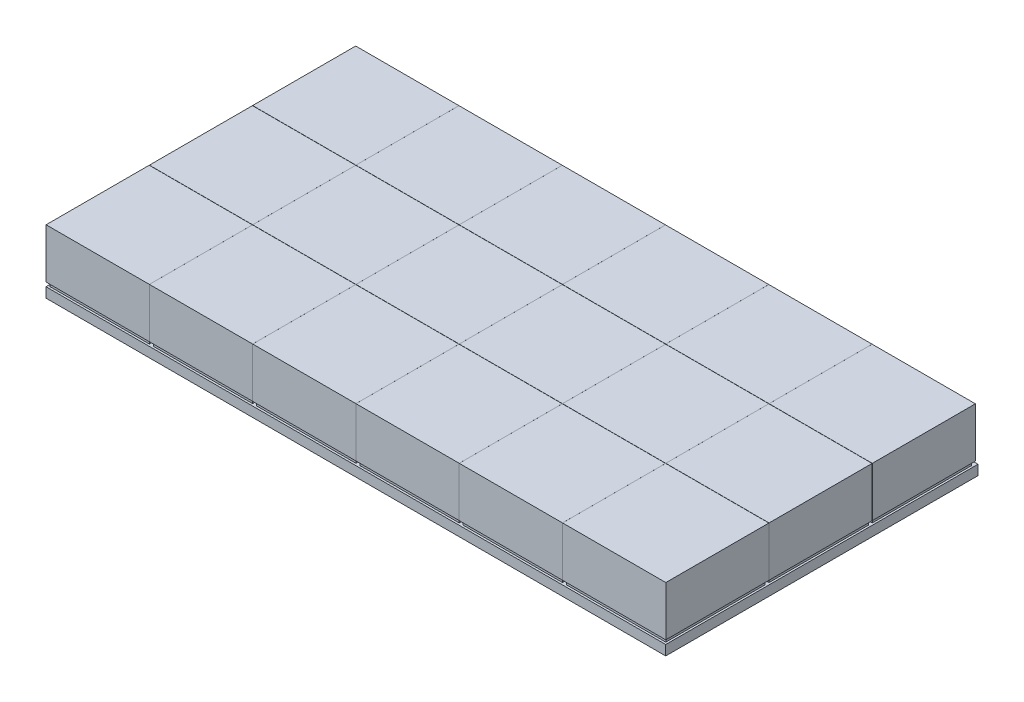
from build123d import *

# Parameters (mm, degrees)
SKETCH1_W                      = 480
SKETCH1_H                      = 270
BOSS_EXTRUDE1_DEPTH            = 5
SKETCH2_W                      = 50
SKETCH2_H                      = 50
BOSS_EXTRUDE3_DEPTH            = 2
LPATTERN1_COUNT                = 5
LPATTERN1_PITCH                = 52
SKETCH3_W                      = 52
SKETCH3_H                      = 51.9
BOSS_EXTRUDE8_DEPTH            = 25
LPATTERN5_COUNT                = 5
LPATTERN5_PITCH                = 52
LPATTERN6_COUNT                = 4
LPATTERN6_PITCH                = 52.01
LPATTERN6_COPY_1_SKETCH_W      = 50
LPATTERN6_COPY_1_SKETCH_H      = 50
LPATTERN6_COPY_1_DEPTH         = 2
LPATTERN6_COPY_2_SKETCH_W      = 50
LPATTERN6_COPY_2_SKETCH_H      = 50
LPATTERN6_COPY_2_DEPTH         = 2
LPATTERN6_COPY_3_SKETCH_W      = 50
LPATTERN6_COPY_3_SKETCH_H      = 50
LPATTERN6_COPY_3_DEPTH         = 2
LPATTERN6_COPY_4_SKETCH_W      = 50
LPATTERN6_COPY_4_SKETCH_H      = 50
LPATTERN6_COPY_4_DEPTH         = 2
LPATTERN6_COPY_5_SKETCH_W      = 50
LPATTERN6_COPY_5_SKETCH_H      = 50
LPATTERN6_COPY_5_DEPTH         = 2
LPATTERN6_COPY_6_SKETCH_W      = 50
LPATTERN6_COPY_6_SKETCH_H      = 50
LPATTERN6_COPY_6_DEPTH         = 2
LPATTERN6_COPY_7_SKETCH_W      = 50
LPATTERN6_COPY_7_SKETCH_H      = 50
LPATTERN6_COPY_7_DEPTH         = 2
LPATTERN6_COPY_8_SKETCH_W      = 50
LPATTERN6_COPY_8_SKETCH_H      = 50
LPATTERN6_COPY_8_DEPTH         = 2
LPATTERN6_COPY_9_SKETCH_W      = 50
LPATTERN6_COPY_9_SKETCH_H      = 50
LPATTERN6_COPY_9_DEPTH         = 2
LPATTERN6_COPY_10_SKETCH_W     = 50
LPATTERN6_COPY_10_SKETCH_H     = 50
LPATTERN6_COPY_10_DEPTH        = 2
LPATTERN6_COPY_11_SKETCH_W     = 50
LPATTERN6_COPY_11_SKETCH_H     = 50
LPATTERN6_COPY_11_DEPTH        = 2
LPATTERN6_COPY_12_SKETCH_W     = 50
LPATTERN6_COPY_12_SKETCH_H     = 50
LPATTERN6_COPY_12_DEPTH        = 2
LPATTERN6_COPY_13_SKETCH_W     = 52
LPATTERN6_COPY_13_SKETCH_H     = 51.9
LPATTERN6_COPY_13_DEPTH        = 25
LPATTERN6_COPY_14_SKETCH_W     = 52
LPATTERN6_COPY_14_SKETCH_H     = 51.9
LPATTERN6_COPY_14_DEPTH        = 25
LPATTERN6_COPY_15_SKETCH_W     = 52
LPATTERN6_COPY_15_SKETCH_H     = 51.9
LPATTERN6_COPY_15_DEPTH        = 25
LPATTERN6_COPY_16_SKETCH_W     = 52
LPATTERN6_COPY_16_SKETCH_H     = 51.9
LPATTERN6_COPY_16_DEPTH        = 25
LPATTERN6_COPY_17_SKETCH_W     = 52
LPATTERN6_COPY_17_SKETCH_H     = 51.9
LPATTERN6_COPY_17_DEPTH        = 25
LPATTERN6_COPY_18_SKETCH_W     = 52
LPATTERN6_COPY_18_SKETCH_H     = 51.9
LPATTERN6_COPY_18_DEPTH        = 25
LPATTERN6_COPY_19_SKETCH_W     = 52
LPATTERN6_COPY_19_SKETCH_H     = 51.9
LPATTERN6_COPY_19_DEPTH        = 25
LPATTERN6_COPY_20_SKETCH_W     = 52
LPATTERN6_COPY_20_SKETCH_H     = 51.9
LPATTERN6_COPY_20_DEPTH        = 25
LPATTERN6_COPY_21_SKETCH_W     = 52
LPATTERN6_COPY_21_SKETCH_H     = 51.9
LPATTERN6_COPY_21_DEPTH        = 25
LPATTERN6_COPY_22_SKETCH_W     = 52
LPATTERN6_COPY_22_SKETCH_H     = 51.9
LPATTERN6_COPY_22_DEPTH        = 25
LPATTERN6_COPY_23_SKETCH_W     = 52
LPATTERN6_COPY_23_SKETCH_H     = 51.9
LPATTERN6_COPY_23_DEPTH        = 25
LPATTERN6_COPY_24_SKETCH_W     = 52
LPATTERN6_COPY_24_SKETCH_H     = 51.9
LPATTERN6_COPY_24_DEPTH        = 25
LPATTERN6_COL_COUNT            = 5
LPATTERN6_COL_PITCH            = 52.01
LPATTERN6_COL_COPY_1_SKETCH_W  = 50
LPATTERN6_COL_COPY_1_SKETCH_H  = 50
LPATTERN6_COL_COPY_1_DEPTH     = 2
LPATTERN6_COL_COPY_2_SKETCH_W  = 50
LPATTERN6_COL_COPY_2_SKETCH_H  = 50
LPATTERN6_COL_COPY_2_DEPTH     = 2
LPATTERN6_COL_COPY_3_SKETCH_W  = 50
LPATTERN6_COL_COPY_3_SKETCH_H  = 50
LPATTERN6_COL_COPY_3_DEPTH     = 2
LPATTERN6_COL_COPY_4_SKETCH_W  = 50
LPATTERN6_COL_COPY_4_SKETCH_H  = 50
LPATTERN6_COL_COPY_4_DEPTH     = 2
LPATTERN6_COL_COPY_5_SKETCH_W  = 50
LPATTERN6_COL_COPY_5_SKETCH_H  = 50
LPATTERN6_COL_COPY_5_DEPTH     = 2
LPATTERN6_COL_COPY_6_SKETCH_W  = 50
LPATTERN6_COL_COPY_6_SKETCH_H  = 50
LPATTERN6_COL_COPY_6_DEPTH     = 2
LPATTERN6_COL_COPY_7_SKETCH_W  = 50
LPATTERN6_COL_COPY_7_SKETCH_H  = 50
LPATTERN6_COL_COPY_7_DEPTH     = 2
LPATTERN6_COL_COPY_8_SKETCH_W  = 50
LPATTERN6_COL_COPY_8_SKETCH_H  = 50
LPATTERN6_COL_COPY_8_DEPTH     = 2
LPATTERN6_COL_COPY_9_SKETCH_W  = 50
LPATTERN6_COL_COPY_9_SKETCH_H  = 50
LPATTERN6_COL_COPY_9_DEPTH     = 2
LPATTERN6_COL_COPY_10_SKETCH_W = 50
LPATTERN6_COL_COPY_10_SKETCH_H = 50
LPATTERN6_COL_COPY_10_DEPTH    = 2
LPATTERN6_COL_COPY_11_SKETCH_W = 50
LPATTERN6_COL_COPY_11_SKETCH_H = 50
LPATTERN6_COL_COPY_11_DEPTH    = 2
LPATTERN6_COL_COPY_12_SKETCH_W = 50
LPATTERN6_COL_COPY_12_SKETCH_H = 50
LPATTERN6_COL_COPY_12_DEPTH    = 2
LPATTERN6_COL_COPY_13_SKETCH_W = 50
LPATTERN6_COL_COPY_13_SKETCH_H = 50
LPATTERN6_COL_COPY_13_DEPTH    = 2
LPATTERN6_COL_COPY_14_SKETCH_W = 50
LPATTERN6_COL_COPY_14_SKETCH_H = 50
LPATTERN6_COL_COPY_14_DEPTH    = 2
LPATTERN6_COL_COPY_15_SKETCH_W = 50
LPATTERN6_COL_COPY_15_SKETCH_H = 50
LPATTERN6_COL_COPY_15_DEPTH    = 2
LPATTERN6_COL_COPY_16_SKETCH_W = 50
LPATTERN6_COL_COPY_16_SKETCH_H = 50
LPATTERN6_COL_COPY_16_DEPTH    = 2
LPATTERN6_COL_COPY_17_SKETCH_W = 52
LPATTERN6_COL_COPY_17_SKETCH_H = 51.9
LPATTERN6_COL_COPY_17_DEPTH    = 25
LPATTERN6_COL_COPY_18_SKETCH_W = 52
LPATTERN6_COL_COPY_18_SKETCH_H = 51.9
LPATTERN6_COL_COPY_18_DEPTH    = 25
LPATTERN6_COL_COPY_19_SKETCH_W = 52
LPATTERN6_COL_COPY_19_SKETCH_H = 51.9
LPATTERN6_COL_COPY_19_DEPTH    = 25
LPATTERN6_COL_COPY_20_SKETCH_W = 52
LPATTERN6_COL_COPY_20_SKETCH_H = 51.9
LPATTERN6_COL_COPY_20_DEPTH    = 25
LPATTERN6_COL_COPY_21_SKETCH_W = 52
LPATTERN6_COL_COPY_21_SKETCH_H = 51.9
LPATTERN6_COL_COPY_21_DEPTH    = 25
LPATTERN6_COL_COPY_22_SKETCH_W = 52
LPATTERN6_COL_COPY_22_SKETCH_H = 51.9
LPATTERN6_COL_COPY_22_DEPTH    = 25
LPATTERN6_COL_COPY_23_SKETCH_W = 52
LPATTERN6_COL_COPY_23_SKETCH_H = 51.9
LPATTERN6_COL_COPY_23_DEPTH    = 25
LPATTERN6_COL_COPY_24_SKETCH_W = 52
LPATTERN6_COL_COPY_24_SKETCH_H = 51.9
LPATTERN6_COL_COPY_24_DEPTH    = 25
LPATTERN6_COL_COPY_25_SKETCH_W = 52
LPATTERN6_COL_COPY_25_SKETCH_H = 51.9
LPATTERN6_COL_COPY_25_DEPTH    = 25
LPATTERN6_COL_COPY_26_SKETCH_W = 52
LPATTERN6_COL_COPY_26_SKETCH_H = 51.9
LPATTERN6_COL_COPY_26_DEPTH    = 25
LPATTERN6_COL_COPY_27_SKETCH_W = 52
LPATTERN6_COL_COPY_27_SKETCH_H = 51.9
LPATTERN6_COL_COPY_27_DEPTH    = 25
LPATTERN6_COL_COPY_28_SKETCH_W = 52
LPATTERN6_COL_COPY_28_SKETCH_H = 51.9
LPATTERN6_COL_COPY_28_DEPTH    = 25
LPATTERN6_COL_COPY_29_SKETCH_W = 52
LPATTERN6_COL_COPY_29_SKETCH_H = 51.9
LPATTERN6_COL_COPY_29_DEPTH    = 25
LPATTERN6_COL_COPY_30_SKETCH_W = 52
LPATTERN6_COL_COPY_30_SKETCH_H = 51.9
LPATTERN6_COL_COPY_30_DEPTH    = 25
LPATTERN6_COL_COPY_31_SKETCH_W = 52
LPATTERN6_COL_COPY_31_SKETCH_H = 51.9
LPATTERN6_COL_COPY_31_DEPTH    = 25
LPATTERN6_COL_COPY_32_SKETCH_W = 52
LPATTERN6_COL_COPY_32_SKETCH_H = 51.9
LPATTERN6_COL_COPY_32_DEPTH    = 25
SKETCH4_W                      = 57.965863992
SKETCH4_H                      = 270
SKETCH4_W_2                    = 109.974703244
SKETCH4_H_2                    = 270.550723286
CUT_EXTRUDE1_DEPTH             = 28
CUT_EXTRUDE1_DEPTH_BACK        = 6
SKETCH5_W                      = 312.059432764
SKETCH5_H                      = 107.948510905
SKETCH5_W_2                    = 312.059780671
SKETCH5_H_2                    = 4.790225888
CUT_EXTRUDE2_DEPTH             = 28
CUT_EXTRUDE2_DEPTH_BACK        = 6


with BuildPart() as part:
    # Sketch1 → Boss-Extrude1 (new body)
    with BuildSketch(Plane(origin=(0, 0, 0), x_dir=(1, 0, 0), z_dir=(0, 1, 0))):
        Rectangle(SKETCH1_W, SKETCH1_H)
    extrude(amount=BOSS_EXTRUDE1_DEPTH)

    # Sketch2 → Boss-Extrude3 (add)
    with BuildSketch(Plane(origin=(0, 5, 0), x_dir=(1, 0, 0), z_dir=(0, 1, 0))):
        with Locations((0, -105)):
            Rectangle(SKETCH2_W, SKETCH2_H)
    boss_extrude3 = extrude(amount=BOSS_EXTRUDE3_DEPTH)

    # LPattern1: Boss-Extrude3 ×5
    with Locations(*[(0, 0, -i * LPATTERN1_PITCH) for i in range(1, LPATTERN1_COUNT)]):
        add(boss_extrude3)

    # Sketch3 → Boss-Extrude8 (add)
    with BuildSketch(Plane(origin=(0, 7, 0), x_dir=(1, 0, 0), z_dir=(0, 1, 0))):
        with Locations((0, -105.05)):
            Rectangle(SKETCH3_W, SKETCH3_H)
    boss_extrude8 = extrude(amount=BOSS_EXTRUDE8_DEPTH)

    # LPattern5: Boss-Extrude8 ×5
    with Locations(*[(0, 0, -i * LPATTERN5_PITCH) for i in range(1, LPATTERN5_COUNT)]):
        add(boss_extrude8)

    # LPattern6: Boss-Extrude3, Boss-Extrude8 ×4
    with Locations(*[(i * LPATTERN6_PITCH, 0, 0) for i in range(1, LPATTERN6_COUNT)]):
        add(boss_extrude3)
        add(boss_extrude8)

    # LPattern6 copy 1 sketch → LPattern6 copy 1 (add)
    with BuildSketch(Plane(origin=(52.01, 5, -52), x_dir=(1, 0, 0), z_dir=(0, 1, 0))):
        with Locations((0, -105)):
            Rectangle(LPATTERN6_COPY_1_SKETCH_W, LPATTERN6_COPY_1_SKETCH_H)
    extrude(amount=LPATTERN6_COPY_1_DEPTH)

    # LPattern6 copy 2 sketch → LPattern6 copy 2 (add)
    with BuildSketch(Plane(origin=(104.02, 5, -52), x_dir=(1, 0, 0), z_dir=(0, 1, 0))):
        with Locations((0, -105)):
            Rectangle(LPATTERN6_COPY_2_SKETCH_W, LPATTERN6_COPY_2_SKETCH_H)
    extrude(amount=LPATTERN6_COPY_2_DEPTH)

    # LPattern6 copy 3 sketch → LPattern6 copy 3 (add)
    with BuildSketch(Plane(origin=(156.03, 5, -52), x_dir=(1, 0, 0), z_dir=(0, 1, 0))):
        with Locations((0, -105)):
            Rectangle(LPATTERN6_COPY_3_SKETCH_W, LPATTERN6_COPY_3_SKETCH_H)
    extrude(amount=LPATTERN6_COPY_3_DEPTH)

    # LPattern6 copy 4 sketch → LPattern6 copy 4 (add)
    with BuildSketch(Plane(origin=(52.01, 5, -104), x_dir=(1, 0, 0), z_dir=(0, 1, 0))):
        with Locations((0, -105)):
            Rectangle(LPATTERN6_COPY_4_SKETCH_W, LPATTERN6_COPY_4_SKETCH_H)
    extrude(amount=LPATTERN6_COPY_4_DEPTH)

    # LPattern6 copy 5 sketch → LPattern6 copy 5 (add)
    with BuildSketch(Plane(origin=(104.02, 5, -104), x_dir=(1, 0, 0), z_dir=(0, 1, 0))):
        with Locations((0, -105)):
            Rectangle(LPATTERN6_COPY_5_SKETCH_W, LPATTERN6_COPY_5_SKETCH_H)
    extrude(amount=LPATTERN6_COPY_5_DEPTH)

    # LPattern6 copy 6 sketch → LPattern6 copy 6 (add)
    with BuildSketch(Plane(origin=(156.03, 5, -104), x_dir=(1, 0, 0), z_dir=(0, 1, 0))):
        with Locations((0, -105)):
            Rectangle(LPATTERN6_COPY_6_SKETCH_W, LPATTERN6_COPY_6_SKETCH_H)
    extrude(amount=LPATTERN6_COPY_6_DEPTH)

    # LPattern6 copy 7 sketch → LPattern6 copy 7 (add)
    with BuildSketch(Plane(origin=(52.01, 5, -156), x_dir=(1, 0, 0), z_dir=(0, 1, 0))):
        with Locations((0, -105)):
            Rectangle(LPATTERN6_COPY_7_SKETCH_W, LPATTERN6_COPY_7_SKETCH_H)
    extrude(amount=LPATTERN6_COPY_7_DEPTH)

    # LPattern6 copy 8 sketch → LPattern6 copy 8 (add)
    with BuildSketch(Plane(origin=(104.02, 5, -156), x_dir=(1, 0, 0), z_dir=(0, 1, 0))):
        with Locations((0, -105)):
            Rectangle(LPATTERN6_COPY_8_SKETCH_W, LPATTERN6_COPY_8_SKETCH_H)
    extrude(amount=LPATTERN6_COPY_8_DEPTH)

    # LPattern6 copy 9 sketch → LPattern6 copy 9 (add)
    with BuildSketch(Plane(origin=(156.03, 5, -156), x_dir=(1, 0, 0), z_dir=(0, 1, 0))):
        with Locations((0, -105)):
            Rectangle(LPATTERN6_COPY_9_SKETCH_W, LPATTERN6_COPY_9_SKETCH_H)
    extrude(amount=LPATTERN6_COPY_9_DEPTH)

    # LPattern6 copy 10 sketch → LPattern6 copy 10 (add)
    with BuildSketch(Plane(origin=(52.01, 5, -208), x_dir=(1, 0, 0), z_dir=(0, 1, 0))):
        with Locations((0, -105)):
            Rectangle(LPATTERN6_COPY_10_SKETCH_W, LPATTERN6_COPY_10_SKETCH_H)
    extrude(amount=LPATTERN6_COPY_10_DEPTH)

    # LPattern6 copy 11 sketch → LPattern6 copy 11 (add)
    with BuildSketch(Plane(origin=(104.02, 5, -208), x_dir=(1, 0, 0), z_dir=(0, 1, 0))):
        with Locations((0, -105)):
            Rectangle(LPATTERN6_COPY_11_SKETCH_W, LPATTERN6_COPY_11_SKETCH_H)
    extrude(amount=LPATTERN6_COPY_11_DEPTH)

    # LPattern6 copy 12 sketch → LPattern6 copy 12 (add)
    with BuildSketch(Plane(origin=(156.03, 5, -208), x_dir=(1, 0, 0), z_dir=(0, 1, 0))):
        with Locations((0, -105)):
            Rectangle(LPATTERN6_COPY_12_SKETCH_W, LPATTERN6_COPY_12_SKETCH_H)
    extrude(amount=LPATTERN6_COPY_12_DEPTH)

    # LPattern6 copy 13 sketch → LPattern6 copy 13 (add)
    with BuildSketch(Plane(origin=(52.01, 7, -52), x_dir=(1, 0, 0), z_dir=(0, 1, 0))):
        with Locations((0, -105.05)):
            Rectangle(LPATTERN6_COPY_13_SKETCH_W, LPATTERN6_COPY_13_SKETCH_H)
    extrude(amount=LPATTERN6_COPY_13_DEPTH)

    # LPattern6 copy 14 sketch → LPattern6 copy 14 (add)
    with BuildSketch(Plane(origin=(104.02, 7, -52), x_dir=(1, 0, 0), z_dir=(0, 1, 0))):
        with Locations((0, -105.05)):
            Rectangle(LPATTERN6_COPY_14_SKETCH_W, LPATTERN6_COPY_14_SKETCH_H)
    extrude(amount=LPATTERN6_COPY_14_DEPTH)

    # LPattern6 copy 15 sketch → LPattern6 copy 15 (add)
    with BuildSketch(Plane(origin=(156.03, 7, -52), x_dir=(1, 0, 0), z_dir=(0, 1, 0))):
        with Locations((0, -105.05)):
            Rectangle(LPATTERN6_COPY_15_SKETCH_W, LPATTERN6_COPY_15_SKETCH_H)
    extrude(amount=LPATTERN6_COPY_15_DEPTH)

    # LPattern6 copy 16 sketch → LPattern6 copy 16 (add)
    with BuildSketch(Plane(origin=(52.01, 7, -104), x_dir=(1, 0, 0), z_dir=(0, 1, 0))):
        with Locations((0, -105.05)):
            Rectangle(LPATTERN6_COPY_16_SKETCH_W, LPATTERN6_COPY_16_SKETCH_H)
    extrude(amount=LPATTERN6_COPY_16_DEPTH)

    # LPattern6 copy 17 sketch → LPattern6 copy 17 (add)
    with BuildSketch(Plane(origin=(104.02, 7, -104), x_dir=(1, 0, 0), z_dir=(0, 1, 0))):
        with Locations((0, -105.05)):
            Rectangle(LPATTERN6_COPY_17_SKETCH_W, LPATTERN6_COPY_17_SKETCH_H)
    extrude(amount=LPATTERN6_COPY_17_DEPTH)

    # LPattern6 copy 18 sketch → LPattern6 copy 18 (add)
    with BuildSketch(Plane(origin=(156.03, 7, -104), x_dir=(1, 0, 0), z_dir=(0, 1, 0))):
        with Locations((0, -105.05)):
            Rectangle(LPATTERN6_COPY_18_SKETCH_W, LPATTERN6_COPY_18_SKETCH_H)
    extrude(amount=LPATTERN6_COPY_18_DEPTH)

    # LPattern6 copy 19 sketch → LPattern6 copy 19 (add)
    with BuildSketch(Plane(origin=(52.01, 7, -156), x_dir=(1, 0, 0), z_dir=(0, 1, 0))):
        with Locations((0, -105.05)):
            Rectangle(LPATTERN6_COPY_19_SKETCH_W, LPATTERN6_COPY_19_SKETCH_H)
    extrude(amount=LPATTERN6_COPY_19_DEPTH)

    # LPattern6 copy 20 sketch → LPattern6 copy 20 (add)
    with BuildSketch(Plane(origin=(104.02, 7, -156), x_dir=(1, 0, 0), z_dir=(0, 1, 0))):
        with Locations((0, -105.05)):
            Rectangle(LPATTERN6_COPY_20_SKETCH_W, LPATTERN6_COPY_20_SKETCH_H)
    extrude(amount=LPATTERN6_COPY_20_DEPTH)

    # LPattern6 copy 21 sketch → LPattern6 copy 21 (add)
    with BuildSketch(Plane(origin=(156.03, 7, -156), x_dir=(1, 0, 0), z_dir=(0, 1, 0))):
        with Locations((0, -105.05)):
            Rectangle(LPATTERN6_COPY_21_SKETCH_W, LPATTERN6_COPY_21_SKETCH_H)
    extrude(amount=LPATTERN6_COPY_21_DEPTH)

    # LPattern6 copy 22 sketch → LPattern6 copy 22 (add)
    with BuildSketch(Plane(origin=(52.01, 7, -208), x_dir=(1, 0, 0), z_dir=(0, 1, 0))):
        with Locations((0, -105.05)):
            Rectangle(LPATTERN6_COPY_22_SKETCH_W, LPATTERN6_COPY_22_SKETCH_H)
    extrude(amount=LPATTERN6_COPY_22_DEPTH)

    # LPattern6 copy 23 sketch → LPattern6 copy 23 (add)
    with BuildSketch(Plane(origin=(104.02, 7, -208), x_dir=(1, 0, 0), z_dir=(0, 1, 0))):
        with Locations((0, -105.05)):
            Rectangle(LPATTERN6_COPY_23_SKETCH_W, LPATTERN6_COPY_23_SKETCH_H)
    extrude(amount=LPATTERN6_COPY_23_DEPTH)

    # LPattern6 copy 24 sketch → LPattern6 copy 24 (add)
    with BuildSketch(Plane(origin=(156.03, 7, -208), x_dir=(1, 0, 0), z_dir=(0, 1, 0))):
        with Locations((0, -105.05)):
            Rectangle(LPATTERN6_COPY_24_SKETCH_W, LPATTERN6_COPY_24_SKETCH_H)
    extrude(amount=LPATTERN6_COPY_24_DEPTH)

    # LPattern6 col: Boss-Extrude3, Boss-Extrude8 ×5
    with Locations(*[(-i * LPATTERN6_COL_PITCH, 0, 0) for i in range(1, LPATTERN6_COL_COUNT)]):
        add(boss_extrude3)
        add(boss_extrude8)

    # LPattern6 col copy 1 sketch → LPattern6 col copy 1 (add)
    with BuildSketch(Plane(origin=(-52.01, 5, -52), x_dir=(1, 0, 0), z_dir=(0, 1, 0))):
        with Locations((0, -105)):
            Rectangle(LPATTERN6_COL_COPY_1_SKETCH_W, LPATTERN6_COL_COPY_1_SKETCH_H)
    extrude(amount=LPATTERN6_COL_COPY_1_DEPTH)

    # LPattern6 col copy 2 sketch → LPattern6 col copy 2 (add)
    with BuildSketch(Plane(origin=(-104.02, 5, -52), x_dir=(1, 0, 0), z_dir=(0, 1, 0))):
        with Locations((0, -105)):
            Rectangle(LPATTERN6_COL_COPY_2_SKETCH_W, LPATTERN6_COL_COPY_2_SKETCH_H)
    extrude(amount=LPATTERN6_COL_COPY_2_DEPTH)

    # LPattern6 col copy 3 sketch → LPattern6 col copy 3 (add)
    with BuildSketch(Plane(origin=(-156.03, 5, -52), x_dir=(1, 0, 0), z_dir=(0, 1, 0))):
        with Locations((0, -105)):
            Rectangle(LPATTERN6_COL_COPY_3_SKETCH_W, LPATTERN6_COL_COPY_3_SKETCH_H)
    extrude(amount=LPATTERN6_COL_COPY_3_DEPTH)

    # LPattern6 col copy 4 sketch → LPattern6 col copy 4 (add)
    with BuildSketch(Plane(origin=(-208.04, 5, -52), x_dir=(1, 0, 0), z_dir=(0, 1, 0))):
        with Locations((0, -105)):
            Rectangle(LPATTERN6_COL_COPY_4_SKETCH_W, LPATTERN6_COL_COPY_4_SKETCH_H)
    extrude(amount=LPATTERN6_COL_COPY_4_DEPTH)

    # LPattern6 col copy 5 sketch → LPattern6 col copy 5 (add)
    with BuildSketch(Plane(origin=(-52.01, 5, -104), x_dir=(1, 0, 0), z_dir=(0, 1, 0))):
        with Locations((0, -105)):
            Rectangle(LPATTERN6_COL_COPY_5_SKETCH_W, LPATTERN6_COL_COPY_5_SKETCH_H)
    extrude(amount=LPATTERN6_COL_COPY_5_DEPTH)

    # LPattern6 col copy 6 sketch → LPattern6 col copy 6 (add)
    with BuildSketch(Plane(origin=(-104.02, 5, -104), x_dir=(1, 0, 0), z_dir=(0, 1, 0))):
        with Locations((0, -105)):
            Rectangle(LPATTERN6_COL_COPY_6_SKETCH_W, LPATTERN6_COL_COPY_6_SKETCH_H)
    extrude(amount=LPATTERN6_COL_COPY_6_DEPTH)

    # LPattern6 col copy 7 sketch → LPattern6 col copy 7 (add)
    with BuildSketch(Plane(origin=(-156.03, 5, -104), x_dir=(1, 0, 0), z_dir=(0, 1, 0))):
        with Locations((0, -105)):
            Rectangle(LPATTERN6_COL_COPY_7_SKETCH_W, LPATTERN6_COL_COPY_7_SKETCH_H)
    extrude(amount=LPATTERN6_COL_COPY_7_DEPTH)

    # LPattern6 col copy 8 sketch → LPattern6 col copy 8 (add)
    with BuildSketch(Plane(origin=(-208.04, 5, -104), x_dir=(1, 0, 0), z_dir=(0, 1, 0))):
        with Locations((0, -105)):
            Rectangle(LPATTERN6_COL_COPY_8_SKETCH_W, LPATTERN6_COL_COPY_8_SKETCH_H)
    extrude(amount=LPATTERN6_COL_COPY_8_DEPTH)

    # LPattern6 col copy 9 sketch → LPattern6 col copy 9 (add)
    with BuildSketch(Plane(origin=(-52.01, 5, -156), x_dir=(1, 0, 0), z_dir=(0, 1, 0))):
        with Locations((0, -105)):
            Rectangle(LPATTERN6_COL_COPY_9_SKETCH_W, LPATTERN6_COL_COPY_9_SKETCH_H)
    extrude(amount=LPATTERN6_COL_COPY_9_DEPTH)

    # LPattern6 col copy 10 sketch → LPattern6 col copy 10 (add)
    with BuildSketch(Plane(origin=(-104.02, 5, -156), x_dir=(1, 0, 0), z_dir=(0, 1, 0))):
        with Locations((0, -105)):
            Rectangle(LPATTERN6_COL_COPY_10_SKETCH_W, LPATTERN6_COL_COPY_10_SKETCH_H)
    extrude(amount=LPATTERN6_COL_COPY_10_DEPTH)

    # LPattern6 col copy 11 sketch → LPattern6 col copy 11 (add)
    with BuildSketch(Plane(origin=(-156.03, 5, -156), x_dir=(1, 0, 0), z_dir=(0, 1, 0))):
        with Locations((0, -105)):
            Rectangle(LPATTERN6_COL_COPY_11_SKETCH_W, LPATTERN6_COL_COPY_11_SKETCH_H)
    extrude(amount=LPATTERN6_COL_COPY_11_DEPTH)

    # LPattern6 col copy 12 sketch → LPattern6 col copy 12 (add)
    with BuildSketch(Plane(origin=(-208.04, 5, -156), x_dir=(1, 0, 0), z_dir=(0, 1, 0))):
        with Locations((0, -105)):
            Rectangle(LPATTERN6_COL_COPY_12_SKETCH_W, LPATTERN6_COL_COPY_12_SKETCH_H)
    extrude(amount=LPATTERN6_COL_COPY_12_DEPTH)

    # LPattern6 col copy 13 sketch → LPattern6 col copy 13 (add)
    with BuildSketch(Plane(origin=(-52.01, 5, -208), x_dir=(1, 0, 0), z_dir=(0, 1, 0))):
        with Locations((0, -105)):
            Rectangle(LPATTERN6_COL_COPY_13_SKETCH_W, LPATTERN6_COL_COPY_13_SKETCH_H)
    extrude(amount=LPATTERN6_COL_COPY_13_DEPTH)

    # LPattern6 col copy 14 sketch → LPattern6 col copy 14 (add)
    with BuildSketch(Plane(origin=(-104.02, 5, -208), x_dir=(1, 0, 0), z_dir=(0, 1, 0))):
        with Locations((0, -105)):
            Rectangle(LPATTERN6_COL_COPY_14_SKETCH_W, LPATTERN6_COL_COPY_14_SKETCH_H)
    extrude(amount=LPATTERN6_COL_COPY_14_DEPTH)

    # LPattern6 col copy 15 sketch → LPattern6 col copy 15 (add)
    with BuildSketch(Plane(origin=(-156.03, 5, -208), x_dir=(1, 0, 0), z_dir=(0, 1, 0))):
        with Locations((0, -105)):
            Rectangle(LPATTERN6_COL_COPY_15_SKETCH_W, LPATTERN6_COL_COPY_15_SKETCH_H)
    extrude(amount=LPATTERN6_COL_COPY_15_DEPTH)

    # LPattern6 col copy 16 sketch → LPattern6 col copy 16 (add)
    with BuildSketch(Plane(origin=(-208.04, 5, -208), x_dir=(1, 0, 0), z_dir=(0, 1, 0))):
        with Locations((0, -105)):
            Rectangle(LPATTERN6_COL_COPY_16_SKETCH_W, LPATTERN6_COL_COPY_16_SKETCH_H)
    extrude(amount=LPATTERN6_COL_COPY_16_DEPTH)

    # LPattern6 col copy 17 sketch → LPattern6 col copy 17 (add)
    with BuildSketch(Plane(origin=(-52.01, 7, -52), x_dir=(1, 0, 0), z_dir=(0, 1, 0))):
        with Locations((0, -105.05)):
            Rectangle(LPATTERN6_COL_COPY_17_SKETCH_W, LPATTERN6_COL_COPY_17_SKETCH_H)
    extrude(amount=LPATTERN6_COL_COPY_17_DEPTH)

    # LPattern6 col copy 18 sketch → LPattern6 col copy 18 (add)
    with BuildSketch(Plane(origin=(-104.02, 7, -52), x_dir=(1, 0, 0), z_dir=(0, 1, 0))):
        with Locations((0, -105.05)):
            Rectangle(LPATTERN6_COL_COPY_18_SKETCH_W, LPATTERN6_COL_COPY_18_SKETCH_H)
    extrude(amount=LPATTERN6_COL_COPY_18_DEPTH)

    # LPattern6 col copy 19 sketch → LPattern6 col copy 19 (add)
    with BuildSketch(Plane(origin=(-156.03, 7, -52), x_dir=(1, 0, 0), z_dir=(0, 1, 0))):
        with Locations((0, -105.05)):
            Rectangle(LPATTERN6_COL_COPY_19_SKETCH_W, LPATTERN6_COL_COPY_19_SKETCH_H)
    extrude(amount=LPATTERN6_COL_COPY_19_DEPTH)

    # LPattern6 col copy 20 sketch → LPattern6 col copy 20 (add)
    with BuildSketch(Plane(origin=(-208.04, 7, -52), x_dir=(1, 0, 0), z_dir=(0, 1, 0))):
        with Locations((0, -105.05)):
            Rectangle(LPATTERN6_COL_COPY_20_SKETCH_W, LPATTERN6_COL_COPY_20_SKETCH_H)
    extrude(amount=LPATTERN6_COL_COPY_20_DEPTH)

    # LPattern6 col copy 21 sketch → LPattern6 col copy 21 (add)
    with BuildSketch(Plane(origin=(-52.01, 7, -104), x_dir=(1, 0, 0), z_dir=(0, 1, 0))):
        with Locations((0, -105.05)):
            Rectangle(LPATTERN6_COL_COPY_21_SKETCH_W, LPATTERN6_COL_COPY_21_SKETCH_H)
    extrude(amount=LPATTERN6_COL_COPY_21_DEPTH)

    # LPattern6 col copy 22 sketch → LPattern6 col copy 22 (add)
    with BuildSketch(Plane(origin=(-104.02, 7, -104), x_dir=(1, 0, 0), z_dir=(0, 1, 0))):
        with Locations((0, -105.05)):
            Rectangle(LPATTERN6_COL_COPY_22_SKETCH_W, LPATTERN6_COL_COPY_22_SKETCH_H)
    extrude(amount=LPATTERN6_COL_COPY_22_DEPTH)

    # LPattern6 col copy 23 sketch → LPattern6 col copy 23 (add)
    with BuildSketch(Plane(origin=(-156.03, 7, -104), x_dir=(1, 0, 0), z_dir=(0, 1, 0))):
        with Locations((0, -105.05)):
            Rectangle(LPATTERN6_COL_COPY_23_SKETCH_W, LPATTERN6_COL_COPY_23_SKETCH_H)
    extrude(amount=LPATTERN6_COL_COPY_23_DEPTH)

    # LPattern6 col copy 24 sketch → LPattern6 col copy 24 (add)
    with BuildSketch(Plane(origin=(-208.04, 7, -104), x_dir=(1, 0, 0), z_dir=(0, 1, 0))):
        with Locations((0, -105.05)):
            Rectangle(LPATTERN6_COL_COPY_24_SKETCH_W, LPATTERN6_COL_COPY_24_SKETCH_H)
    extrude(amount=LPATTERN6_COL_COPY_24_DEPTH)

    # LPattern6 col copy 25 sketch → LPattern6 col copy 25 (add)
    with BuildSketch(Plane(origin=(-52.01, 7, -156), x_dir=(1, 0, 0), z_dir=(0, 1, 0))):
        with Locations((0, -105.05)):
            Rectangle(LPATTERN6_COL_COPY_25_SKETCH_W, LPATTERN6_COL_COPY_25_SKETCH_H)
    extrude(amount=LPATTERN6_COL_COPY_25_DEPTH)

    # LPattern6 col copy 26 sketch → LPattern6 col copy 26 (add)
    with BuildSketch(Plane(origin=(-104.02, 7, -156), x_dir=(1, 0, 0), z_dir=(0, 1, 0))):
        with Locations((0, -105.05)):
            Rectangle(LPATTERN6_COL_COPY_26_SKETCH_W, LPATTERN6_COL_COPY_26_SKETCH_H)
    extrude(amount=LPATTERN6_COL_COPY_26_DEPTH)

    # LPattern6 col copy 27 sketch → LPattern6 col copy 27 (add)
    with BuildSketch(Plane(origin=(-156.03, 7, -156), x_dir=(1, 0, 0), z_dir=(0, 1, 0))):
        with Locations((0, -105.05)):
            Rectangle(LPATTERN6_COL_COPY_27_SKETCH_W, LPATTERN6_COL_COPY_27_SKETCH_H)
    extrude(amount=LPATTERN6_COL_COPY_27_DEPTH)

    # LPattern6 col copy 28 sketch → LPattern6 col copy 28 (add)
    with BuildSketch(Plane(origin=(-208.04, 7, -156), x_dir=(1, 0, 0), z_dir=(0, 1, 0))):
        with Locations((0, -105.05)):
            Rectangle(LPATTERN6_COL_COPY_28_SKETCH_W, LPATTERN6_COL_COPY_28_SKETCH_H)
    extrude(amount=LPATTERN6_COL_COPY_28_DEPTH)

    # LPattern6 col copy 29 sketch → LPattern6 col copy 29 (add)
    with BuildSketch(Plane(origin=(-52.01, 7, -208), x_dir=(1, 0, 0), z_dir=(0, 1, 0))):
        with Locations((0, -105.05)):
            Rectangle(LPATTERN6_COL_COPY_29_SKETCH_W, LPATTERN6_COL_COPY_29_SKETCH_H)
    extrude(amount=LPATTERN6_COL_COPY_29_DEPTH)

    # LPattern6 col copy 30 sketch → LPattern6 col copy 30 (add)
    with BuildSketch(Plane(origin=(-104.02, 7, -208), x_dir=(1, 0, 0), z_dir=(0, 1, 0))):
        with Locations((0, -105.05)):
            Rectangle(LPATTERN6_COL_COPY_30_SKETCH_W, LPATTERN6_COL_COPY_30_SKETCH_H)
    extrude(amount=LPATTERN6_COL_COPY_30_DEPTH)

    # LPattern6 col copy 31 sketch → LPattern6 col copy 31 (add)
    with BuildSketch(Plane(origin=(-156.03, 7, -208), x_dir=(1, 0, 0), z_dir=(0, 1, 0))):
        with Locations((0, -105.05)):
            Rectangle(LPATTERN6_COL_COPY_31_SKETCH_W, LPATTERN6_COL_COPY_31_SKETCH_H)
    extrude(amount=LPATTERN6_COL_COPY_31_DEPTH)

    # LPattern6 col copy 32 sketch → LPattern6 col copy 32 (add)
    with BuildSketch(Plane(origin=(-208.04, 7, -208), x_dir=(1, 0, 0), z_dir=(0, 1, 0))):
        with Locations((0, -105.05)):
            Rectangle(LPATTERN6_COL_COPY_32_SKETCH_W, LPATTERN6_COL_COPY_32_SKETCH_H)
    extrude(amount=LPATTERN6_COL_COPY_32_DEPTH)

    # Sketch4 → Cut-Extrude1 (cut, two sides)
    with BuildSketch(Plane(origin=(0, 5, 0), x_dir=(1, 0, 0), z_dir=(0, 1, 0))) as cut_extrude1_sk:
        with Locations((-211.017068004, 0)):
            Rectangle(SKETCH4_W, SKETCH4_H)
        with Locations((185.012648378, 0.275361643)):
            Rectangle(SKETCH4_W_2, SKETCH4_H_2)
    extrude(amount=CUT_EXTRUDE1_DEPTH, mode=Mode.SUBTRACT)
    extrude(cut_extrude1_sk.sketch, amount=-CUT_EXTRUDE1_DEPTH_BACK, mode=Mode.SUBTRACT)

    # Sketch5 → Cut-Extrude2 (cut, two sides)
    with BuildSketch(Plane(origin=(0, 5, 0), x_dir=(1, 0, 0), z_dir=(0, 1, 0))) as cut_extrude2_sk:
        with Locations((-26.004419626, -81.025744547)):
            Rectangle(SKETCH5_W, SKETCH5_H)
        with Locations((-26.004593579, 132.604887056)):
            Rectangle(SKETCH5_W_2, SKETCH5_H_2)
    extrude(amount=CUT_EXTRUDE2_DEPTH, mode=Mode.SUBTRACT)
    extrude(cut_extrude2_sk.sketch, amount=-CUT_EXTRUDE2_DEPTH_BACK, mode=Mode.SUBTRACT)


solid = part.part
